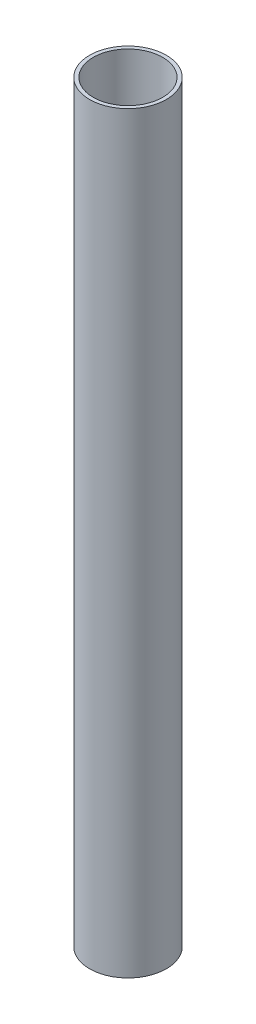
from build123d import *

# Parameters (mm, degrees)
SKETCH1_R           = 21
SKETCH1_R_2         = 19
BOSS_EXTRUDE1_DEPTH = 412


with BuildPart() as part:
    # Sketch1 → Boss-Extrude1 (new body)
    with BuildSketch(Plane(origin=(0, 0, 0), x_dir=(1, 0, 0), z_dir=(0, 1, 0))):
        Circle(SKETCH1_R)
        Circle(SKETCH1_R_2, mode=Mode.SUBTRACT)
    extrude(amount=BOSS_EXTRUDE1_DEPTH)


solid = part.part
